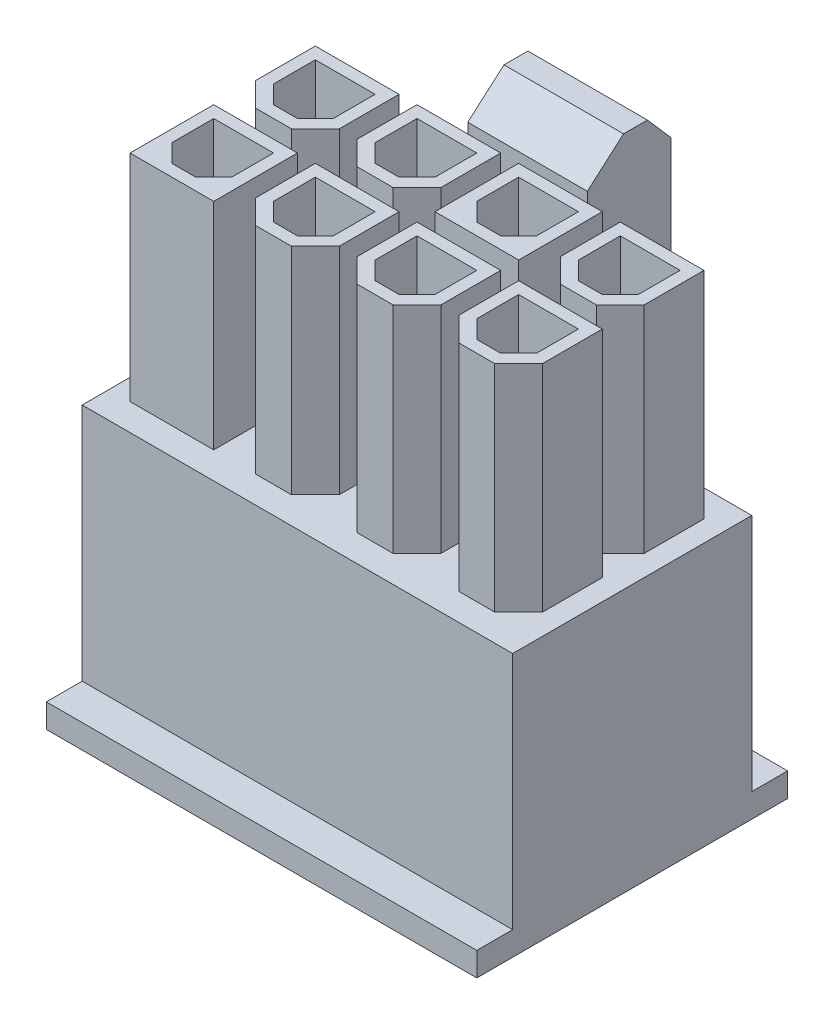
from build123d import *

# Parameters (mm, degrees)
SKIZZE1_W                       = 10
SKIZZE1_H                       = 11
AUFSATZ_LINEAR_AUSTRAGEN1_DEPTH = 9
SKIZZE2_W                       = 1.5
SKIZZE2_H                       = 1
AUFSATZ_LINEAR_AUSTRAGEN2_DEPTH = 9
AUFSATZ_LINEAR_AUSTRAGEN3_DEPTH = 4
SKIZZE4_W                       = 5
SKIZZE4_H                       = 1.5
SCHNITT_LINEAR_AUSTRAGEN1_DEPTH = 12
AUFSATZ_LINEAR_AUSTRAGEN4_DEPTH = 2.5
SKIZZE6_W                       = 3.75
SKIZZE6_H                       = 3.75
SCHNITT_LINEAR_AUSTRAGEN2_DEPTH = 10
LINEARES_MUSTER1_COUNT          = 4
LINEARES_MUSTER1_PITCH          = 4.25
LINEARES_MUSTER1_COUNT_DIR2     = 2
LINEARES_MUSTER1_PITCH_DIR2     = 4.25
SKIZZE7_W                       = 3.5
SKIZZE7_H                       = 3.5
AUFSATZ_LINEAR_AUSTRAGEN5_DEPTH = 9
LINEARES_MUSTER2_COUNT          = 3
LINEARES_MUSTER2_PITCH          = 4.25
LINEARES_MUSTER2_COUNT_DIR2     = 2
LINEARES_MUSTER2_PITCH_DIR2     = 4.25
AUFSATZ_LINEAR_AUSTRAGEN7_DEPTH = 9
LINEARES_MUSTER4_COUNT          = 4
LINEARES_MUSTER4_PITCH          = 4.25
LINEARES_MUSTER4_COUNT_DIR2     = 2
LINEARES_MUSTER4_PITCH_DIR2     = 4.25
SCHNITT_LINEAR_AUSTRAGEN4_DEPTH = 21
LINEARES_MUSTER6_COUNT          = 4
LINEARES_MUSTER6_PITCH          = 4.25
LINEARES_MUSTER6_COUNT_DIR2     = 2
LINEARES_MUSTER6_PITCH_DIR2     = 4.25


with BuildPart() as part:
    # Skizze1 → Aufsatz-Linear austragen1 (new body, symmetric)
    with BuildSketch(Plane(origin=(0, 0, 0), x_dir=(0, 0, -1), z_dir=(1, 0, 0))):
        with Locations((0, 5.5)):
            Rectangle(SKIZZE1_W, SKIZZE1_H)
    extrude(amount=AUFSATZ_LINEAR_AUSTRAGEN1_DEPTH, both=True)

    # Skizze2 → Aufsatz-Linear austragen2 (add, symmetric)
    with BuildSketch(Plane(origin=(0, 0, 0), x_dir=(0, 0, -1), z_dir=(1, 0, 0))):
        with Locations((-5.75, 0.5)):
            Rectangle(SKIZZE2_W, SKIZZE2_H)
        with Locations((5.75, 0.5)):
            Rectangle(SKIZZE2_W, SKIZZE2_H)
    extrude(amount=AUFSATZ_LINEAR_AUSTRAGEN2_DEPTH, both=True)

    # Skizze3 → Aufsatz-Linear austragen3 (add, symmetric)
    with BuildSketch(Plane(origin=(0, 0, 0), x_dir=(0, 0, -1), z_dir=(1, 0, 0))):
        with BuildLine():
            Line((5, 11), (5.571713615, 11))
            ThreePointArc((5.571713615, 11), (5.836038655, 10.149642784), (6.535856807, 9.598979842))
            ThreePointArc((6.535856807, 9.598979842), (7.23567496, 9.048316901), (7.5, 8.197959685))
            Line((7.5, 8.197959685), (7.5, 5.197959685))
            Line((7.5, 5.197959685), (8.5, 4))
            Line((8.5, 4), (8.5, 2))
            Line((8.5, 2), (6.5, 2))
            Line((6.5, 2), (6.5, 8))
            Line((6.5, 8), (5, 8))
            Line((5, 8), (5, 11))
        make_face()
    extrude(amount=AUFSATZ_LINEAR_AUSTRAGEN3_DEPTH, both=True)

    # Skizze4 → Schnitt-Linear austragen1 (cut, through all)
    with BuildSketch(Plane.XZ):
        with Locations((0, -5.75)):
            Rectangle(SKIZZE4_W, SKIZZE4_H)
    extrude(amount=-SCHNITT_LINEAR_AUSTRAGEN1_DEPTH, mode=Mode.SUBTRACT)

    # Skizze5 → Aufsatz-Linear austragen4 (add, symmetric)
    with BuildSketch(Plane(origin=(0, 0, 0), x_dir=(0, 0, -1), z_dir=(1, 0, 0))):
        Polygon((8.123516438, 4.451012129), (8.123516438, 19.870653012), (7.136310593, 21), (6.136310593, 21), (4.623516438, 19.677608169), (4.623516438, 17.677608169), (6.123516438, 17.677608169), (6.5, 8), (6.5, 2), align=None)
    extrude(amount=AUFSATZ_LINEAR_AUSTRAGEN4_DEPTH, both=True)

    # Skizze6 → Schnitt-Linear austragen2 (cut)
    with BuildSketch(Plane.XZ):
        with Locations((-6.375, -2.125)):
            Rectangle(SKIZZE6_W, SKIZZE6_H)
    schnitt_linear_austragen2 = extrude(amount=-SCHNITT_LINEAR_AUSTRAGEN2_DEPTH, mode=Mode.SUBTRACT)

    # Lineares Muster1: Schnitt-Linear austragen2 4 × 2
    with Locations(*[(i * LINEARES_MUSTER1_PITCH, 0, j * LINEARES_MUSTER1_PITCH_DIR2) for i in range(LINEARES_MUSTER1_COUNT) for j in range(LINEARES_MUSTER1_COUNT_DIR2) if (i, j) != (0, 0)]):
        add(schnitt_linear_austragen2, mode=Mode.SUBTRACT)

    # Skizze7 → Aufsatz-Linear austragen5 (add)
    with BuildSketch(Plane(origin=(0, 11, 0), x_dir=(1, 0, 0), z_dir=(0, 1, 0))):
        with Locations((-6.375, -2.125)):
            Rectangle(SKIZZE7_W, SKIZZE7_H)
    aufsatz_linear_austragen5 = extrude(amount=AUFSATZ_LINEAR_AUSTRAGEN5_DEPTH)

    # Lineares Muster2: Aufsatz-Linear austragen5 3 × 2, 4 skipped
    with Locations(*[(i * LINEARES_MUSTER2_PITCH, 0, -j * LINEARES_MUSTER2_PITCH_DIR2) for i in range(LINEARES_MUSTER2_COUNT) for j in range(LINEARES_MUSTER2_COUNT_DIR2) if (i, j) not in ((0, 0), (0, 1), (1, 0), (1, 1), (2, 0))]):
        add(aufsatz_linear_austragen5)

    # Skizze10 → Aufsatz-Linear austragen7 (add)
    with BuildSketch(Plane(origin=(0, 11, 0), x_dir=(1, 0, 0), z_dir=(0, 1, 0))):
        Polygon((-4.625, 1.375), (-5.625, 0.375), (-7.125, 0.375), (-8.125, 1.375), (-8.125, 3.875), (-4.625, 3.875), align=None)
    aufsatz_linear_austragen7 = extrude(amount=AUFSATZ_LINEAR_AUSTRAGEN7_DEPTH)

    # Lineares Muster4: Aufsatz-Linear austragen7 4 × 2, 2 skipped
    with Locations(*[(i * LINEARES_MUSTER4_PITCH, 0, j * LINEARES_MUSTER4_PITCH_DIR2) for i in range(LINEARES_MUSTER4_COUNT) for j in range(LINEARES_MUSTER4_COUNT_DIR2) if (i, j) not in ((0, 0), (0, 1), (2, 0))]):
        add(aufsatz_linear_austragen7)

    # Skizze12 → Schnitt-Linear austragen4 (cut, through all)
    with BuildSketch(Plane(origin=(0, 20, 0), x_dir=(1, 0, 0), z_dir=(0, 1, 0))):
        Polygon((-5.875, 0.875), (-5.125, 1.625), (-5.125, 3.375), (-7.625, 3.375), (-7.625, 1.625), (-6.875, 0.875), align=None)
    schnitt_linear_austragen4 = extrude(amount=-SCHNITT_LINEAR_AUSTRAGEN4_DEPTH, mode=Mode.SUBTRACT)

    # Lineares Muster6: Schnitt-Linear austragen4 4 × 2
    with Locations(*[(i * LINEARES_MUSTER6_PITCH, 0, j * LINEARES_MUSTER6_PITCH_DIR2) for i in range(LINEARES_MUSTER6_COUNT) for j in range(LINEARES_MUSTER6_COUNT_DIR2) if (i, j) != (0, 0)]):
        add(schnitt_linear_austragen4, mode=Mode.SUBTRACT)


solid = part.part
